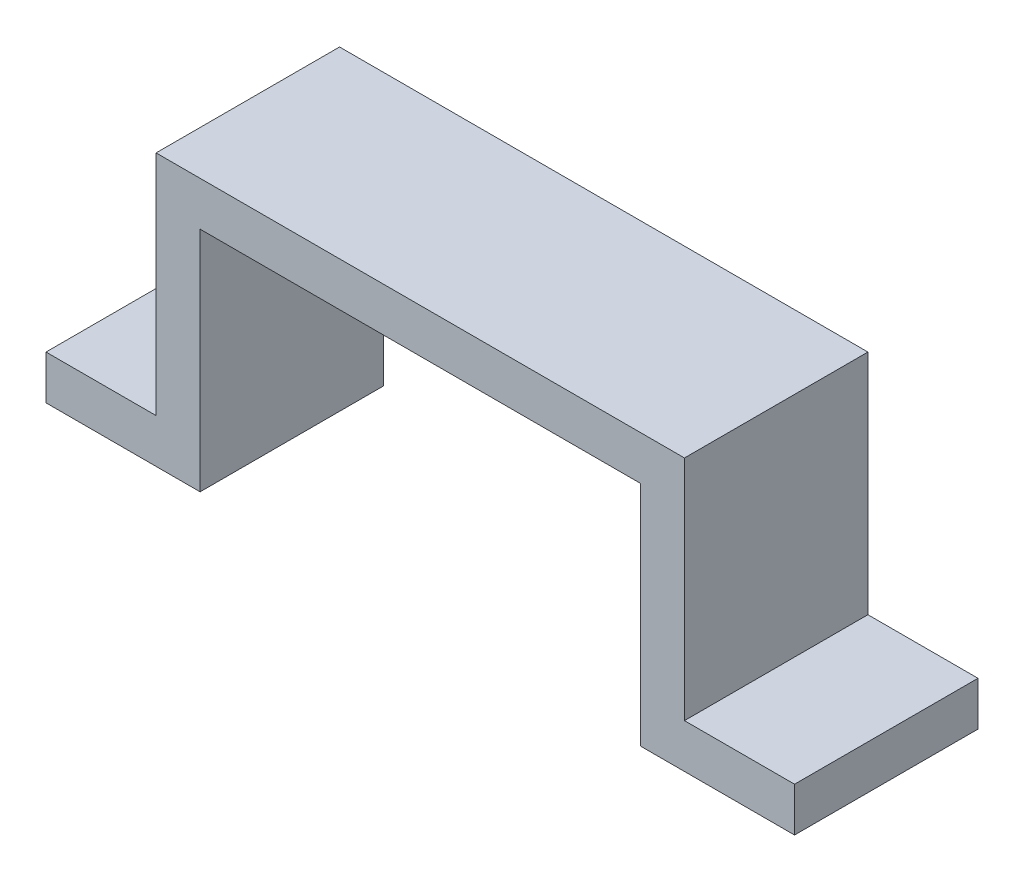
from build123d import *

# Parameters (mm, degrees)
BOSS_EXTRUDE1_DEPTH = 25


with BuildPart() as part:
    # Sketch1 → Boss-Extrude1 (new body)
    with BuildSketch(Plane.XY):
        Polygon((0, 0), (15, 0), (15, 31), (87, 31), (87, 0), (102, 0), (102, -6), (81, -6), (81, 25), (21, 25), (21, -6), (0, -6), align=None)
    extrude(amount=BOSS_EXTRUDE1_DEPTH)


solid = part.part
